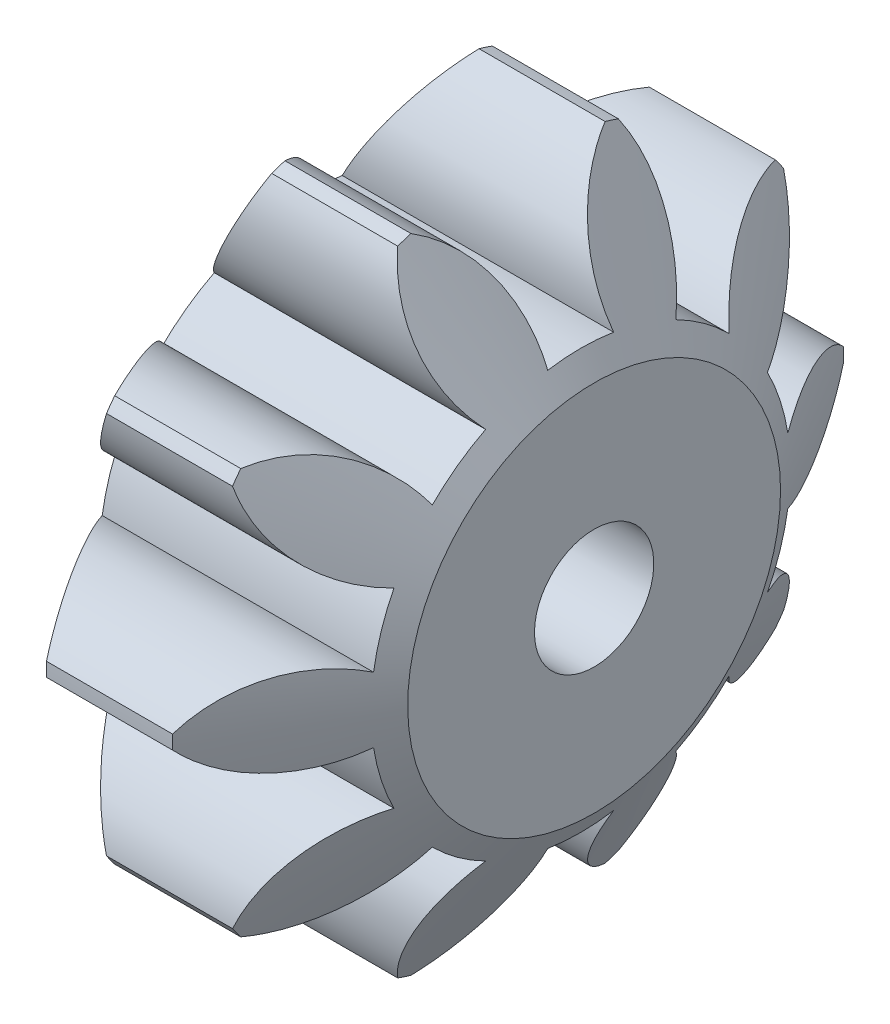
from build123d import *

# Parameters (mm, degrees)
BASPROSKE_W        = 8
BASPROSKE_H        = 9
TOOTHCUT_DEPTH     = 16.033296378
TEETHCUTS_COUNT    = 10
TEETHCUTS_ANGLE    = 324
BORSKE_R           = 1.5
BORE_DEPTH         = 50.0000508
SKETCH2_R          = 1.6
CUT_EXTRUDE1_DEPTH = 10


with BuildPart() as part:
    # BasProSke → Base-Revolve (revolve)
    with BuildSketch(Plane(origin=(0, 0, 0), x_dir=(1, 0, 0), z_dir=(0, 1, 0)), mode=Mode.PRIVATE) as base_revolve_sk:
        with Locations((4, 4.5)):
            Rectangle(BASPROSKE_W, BASPROSKE_H)
    revolve(base_revolve_sk.sketch.rotate(Axis((-10, 0, 0), (1, 0, 0)), 180), axis=Axis((-10, 0, 0), (1, 0, 0)))

    # TooCutSke → ToothCut (cut, through all)
    with BuildSketch(Plane(origin=(0, 0, 0), x_dir=(0, 0, -1), z_dir=(1, 0, 0))):
        with BuildLine():
            ThreePointArc((0.883878355, 5.554109745), (0, 5.624), (-0.883878355, 5.554109745))
            ThreePointArc((-0.883878355, 5.554109745), (-1.258245767, 7.379188248), (-2.637816971, 8.631324741))
            ThreePointArc((-2.637816971, 8.631324741), (0, 9.0254), (2.637816971, 8.631324741))
            ThreePointArc((2.637816971, 8.631324741), (1.258245767, 7.379188248), (0.883878355, 5.554109745))
        make_face()
    toothcut = extrude(amount=TOOTHCUT_DEPTH, mode=Mode.SUBTRACT)

    # TeethCuts: ToothCut ×10 about axis
    teethcuts_axis = Axis((-10, 0, 0), (1, 0, 0))
    for i in range(1, TEETHCUTS_COUNT):
        add(toothcut.rotate(teethcuts_axis, i * TEETHCUTS_ANGLE / (TEETHCUTS_COUNT - 1)), mode=Mode.SUBTRACT)

    # BorSke → Bore (cut, symmetric)
    with BuildSketch(Plane(origin=(0, 0, 0), x_dir=(0, 0, -1), z_dir=(1, 0, 0))):
        with Locations(Location((0, 0, 0), (0, 0, 180))):
            Circle(BORSKE_R)
    extrude(amount=BORE_DEPTH, both=True, mode=Mode.SUBTRACT)

    # Sketch1 → Cut-Revolve1 (revolve, cut)
    with BuildSketch(Plane(origin=(0, 0, 0), x_dir=(1, 0, 0), z_dir=(0, 1, 0)), mode=Mode.PRIVATE) as cut_revolve1_sk:
        Polygon((0, -5), (3.946553979, -11.835632006), (4.053446021, -11.835632006), (8, -5), (10.092806182, -15.908435196), (-2.21285392, -14.524958616), align=None)
    revolve(cut_revolve1_sk.sketch.rotate(Axis((0, 0, 0), (-1, 0, 0)), 180), axis=Axis((0, 0, 0), (-1, 0, 0)), mode=Mode.SUBTRACT)

    # Sketch2 → Cut-Extrude1 (cut)
    with BuildSketch(Plane.ZY):
        Circle(SKETCH2_R)
    extrude(amount=-CUT_EXTRUDE1_DEPTH, mode=Mode.SUBTRACT)


solid = part.part
